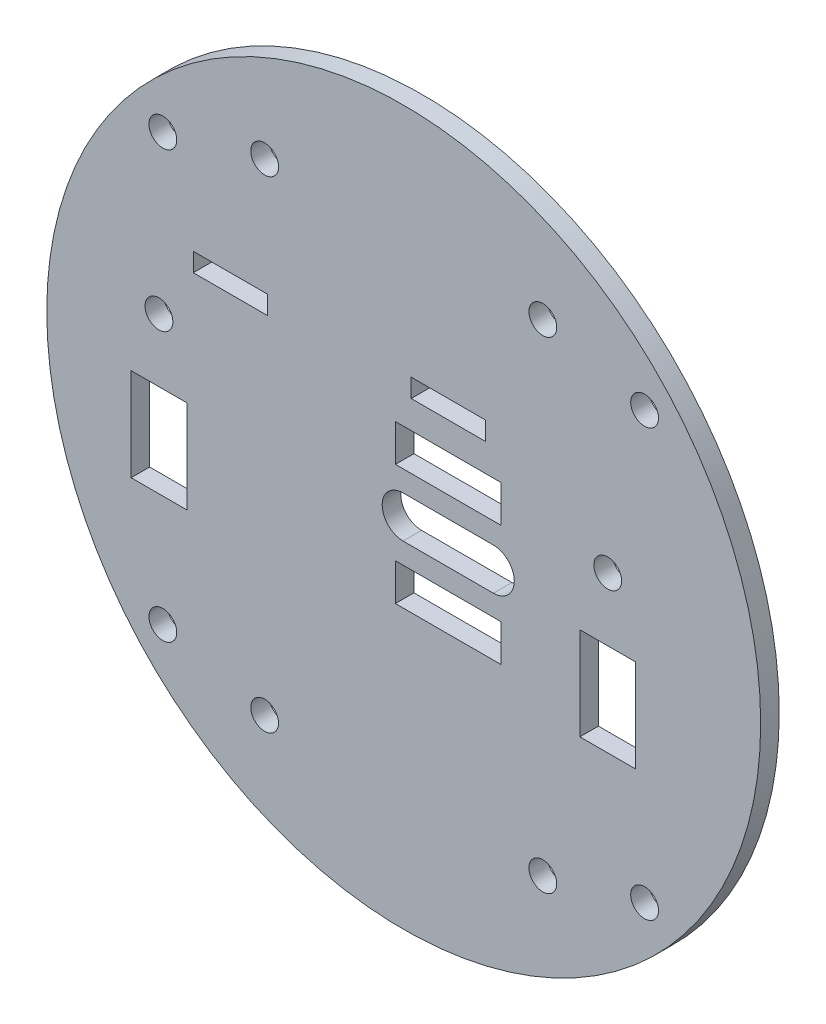
from build123d import *

# Parameters (mm, degrees)
MODEL_R             = 38.5
MODEL_R_2           = 1.5
MODEL_W             = 8
MODEL_H             = 2
MODEL_W_2           = 11.4
MODEL_H_2           = 4
MODEL_W_3           = 6
MODEL_H_3           = 10
BOSS_EXTRUDE1_DEPTH = 2


with BuildPart() as part:
    # Model → Boss-Extrude1 (new body)
    with BuildSketch(Plane.XY):
        with Locations((0.073397172, 0)):
            Circle(MODEL_R)
        with Locations((-14.926602828, -25.980762114)):
            Circle(MODEL_R_2, mode=Mode.SUBTRACT)
        with Locations((-14.926602828, 25.980762114)):
            Circle(MODEL_R_2, mode=Mode.SUBTRACT)
        with Locations((15.073397172, 25.980762114)):
            Circle(MODEL_R_2, mode=Mode.SUBTRACT)
        with Locations((15.073397172, -25.980762114)):
            Circle(MODEL_R_2, mode=Mode.SUBTRACT)
        with Locations((-26.326602828, 5.806018336)):
            Circle(MODEL_R_2, mode=Mode.SUBTRACT)
        with Locations((22.073397172, 5.806018336)):
            Circle(MODEL_R_2, mode=Mode.SUBTRACT)
        with Locations((26.054159286, -23)):
            Circle(MODEL_R_2, mode=Mode.SUBTRACT)
        with Locations((-25.907364941, -23)):
            Circle(MODEL_R_2, mode=Mode.SUBTRACT)
        with Locations((26.054159286, 23)):
            Circle(MODEL_R_2, mode=Mode.SUBTRACT)
        with Locations((-25.907364941, 23)):
            Circle(MODEL_R_2, mode=Mode.SUBTRACT)
        with Locations((-18.626602828, 12.5)):
            Rectangle(MODEL_W, MODEL_H, mode=Mode.SUBTRACT)
        with Locations((4.873397172, 12.5)):
            Rectangle(MODEL_W, MODEL_H, mode=Mode.SUBTRACT)
        with Locations((4.873397172, -6.5)):
            Rectangle(MODEL_W_2, MODEL_H_2, mode=Mode.SUBTRACT)
        with Locations((4.873397172, 6.5)):
            Rectangle(MODEL_W_2, MODEL_H_2, mode=Mode.SUBTRACT)
        with BuildLine():
            Line((0, -2.25), (9.746794345, -2.25))
            ThreePointArc((9.746794345, -2.25), (11.996794345, 0), (9.746794345, 2.25))
            Line((9.746794345, 2.25), (0, 2.25))
            ThreePointArc((0, 2.25), (-2.25, 0), (0, -2.25))
        make_face(mode=Mode.SUBTRACT)
        with Locations((-26.326602828, -6)):
            Rectangle(MODEL_W_3, MODEL_H_3, mode=Mode.SUBTRACT)
        with Locations((22.073397172, -6)):
            Rectangle(MODEL_W_3, MODEL_H_3, mode=Mode.SUBTRACT)
    extrude(amount=BOSS_EXTRUDE1_DEPTH)


solid = part.part
